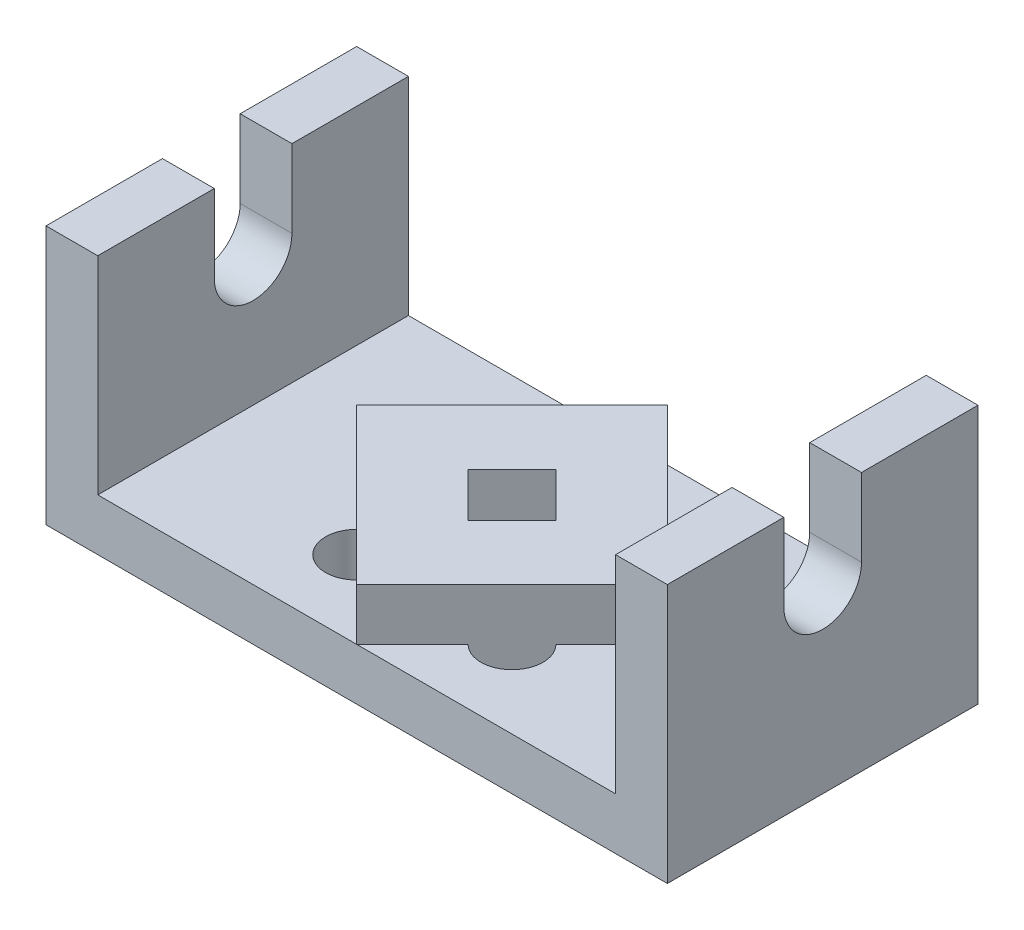
from build123d import *

# Parameters (mm, degrees)
BOSS_EXTRUDE1_DEPTH = 30
CUT_EXTRUDE1_DEPTH  = 121
BOSS_EXTRUDE2_DEPTH = 10
CUT_EXTRUDE2_DEPTH  = 21
CUT_EXTRUDE3_DEPTH  = 21


with BuildPart() as part:
    # Sketch1 → Boss-Extrude1 (new body, symmetric)
    with BuildSketch(Plane.XY):
        Polygon((-60, 0), (60, 0), (60, 50), (50, 50), (50, 10), (-50, 10), (-50, 50), (-60, 50), align=None)
    extrude(amount=BOSS_EXTRUDE1_DEPTH, both=True)

    # Sketch2 → Cut-Extrude1 (cut, through all)
    with BuildSketch(Plane(origin=(60, 0, 0), x_dir=(0, 0, -1), z_dir=(1, 0, 0))):
        with BuildLine():
            Line((-7.5, 35), (-7.5, 50))
            Line((-7.5, 50), (7.5, 50))
            Line((7.5, 50), (7.5, 35))
            ThreePointArc((7.5, 35), (0, 27.5), (-7.5, 35))
        make_face()
    extrude(amount=-CUT_EXTRUDE1_DEPTH, mode=Mode.SUBTRACT)

    # Sketch3 → Boss-Extrude2 (add)
    with BuildSketch(Plane(origin=(0, 10, 0), x_dir=(1, 0, 0), z_dir=(0, 1, 0))):
        Polygon((0, 30), (30, 0), (0, -30), (-30, 0), align=None)
    extrude(amount=BOSS_EXTRUDE2_DEPTH)

    # Sketch4 → Cut-Extrude2 (cut, through all)
    with BuildSketch(Plane(origin=(0, 20, 0), x_dir=(1, 0, 0), z_dir=(0, 1, 0))):
        Polygon((0, 8.485281374), (8.485281374, 0), (0, -8.485281374), (-8.485281374, 0), align=None)
    extrude(amount=-CUT_EXTRUDE2_DEPTH, mode=Mode.SUBTRACT)

    # Sketch5 → Cut-Extrude3 (cut, through all)
    with BuildSketch(Plane(origin=(0, 20, 0), x_dir=(1, 0, 0), z_dir=(0, 1, 0))):
        with BuildLine():
            Line((10.757359313, 19.242640687), (19.242640687, 10.757359313))
            ThreePointArc((19.242640687, 10.757359313), (19.242640687, 19.242640687), (10.757359313, 19.242640687))
        make_face()
        with BuildLine():
            Line((19.242640687, -10.757359313), (10.757359313, -19.242640687))
            ThreePointArc((10.757359313, -19.242640687), (19.242640687, -19.242640687), (19.242640687, -10.757359313))
        make_face()
        with BuildLine():
            Line((-10.757359313, -19.242640687), (-19.242640687, -10.757359313))
            ThreePointArc((-19.242640687, -10.757359313), (-19.242640687, -19.242640687), (-10.757359313, -19.242640687))
        make_face()
        with BuildLine():
            Line((-19.242640687, 10.757359313), (-10.757359313, 19.242640687))
            ThreePointArc((-10.757359313, 19.242640687), (-19.242640687, 19.242640687), (-19.242640687, 10.757359313))
        make_face()
    extrude(amount=-CUT_EXTRUDE3_DEPTH, mode=Mode.SUBTRACT)


solid = part.part
